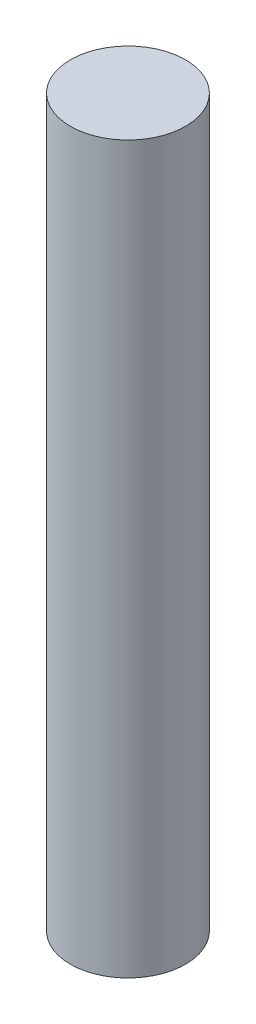
from build123d import *

# Parameters (mm, degrees)
SKETCH1_R           = 12.7
BOSS_EXTRUDE1_DEPTH = 160


with BuildPart() as part:
    # Sketch1 → Boss-Extrude1 (new body)
    with BuildSketch(Plane(origin=(0, 0, 0), x_dir=(1, 0, 0), z_dir=(0, 1, 0))):
        Circle(SKETCH1_R)
    extrude(amount=BOSS_EXTRUDE1_DEPTH)


solid = part.part
